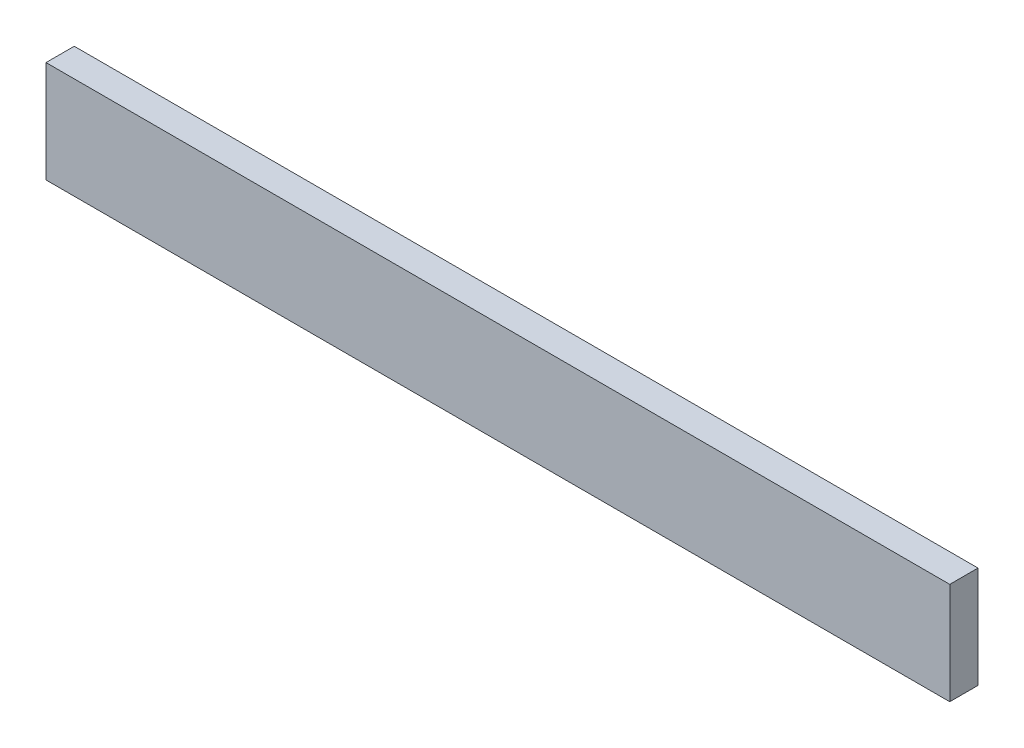
from build123d import *

# Parameters (mm, degrees)
SKETCH1_W           = 800
SKETCH1_H           = 90
BOSS_EXTRUDE1_DEPTH = 25


with BuildPart() as part:
    # Sketch1 → Boss-Extrude1 (new body)
    with BuildSketch(Plane.XY):
        with Locations((400, 45)):
            Rectangle(SKETCH1_W, SKETCH1_H)
    extrude(amount=BOSS_EXTRUDE1_DEPTH)


solid = part.part
